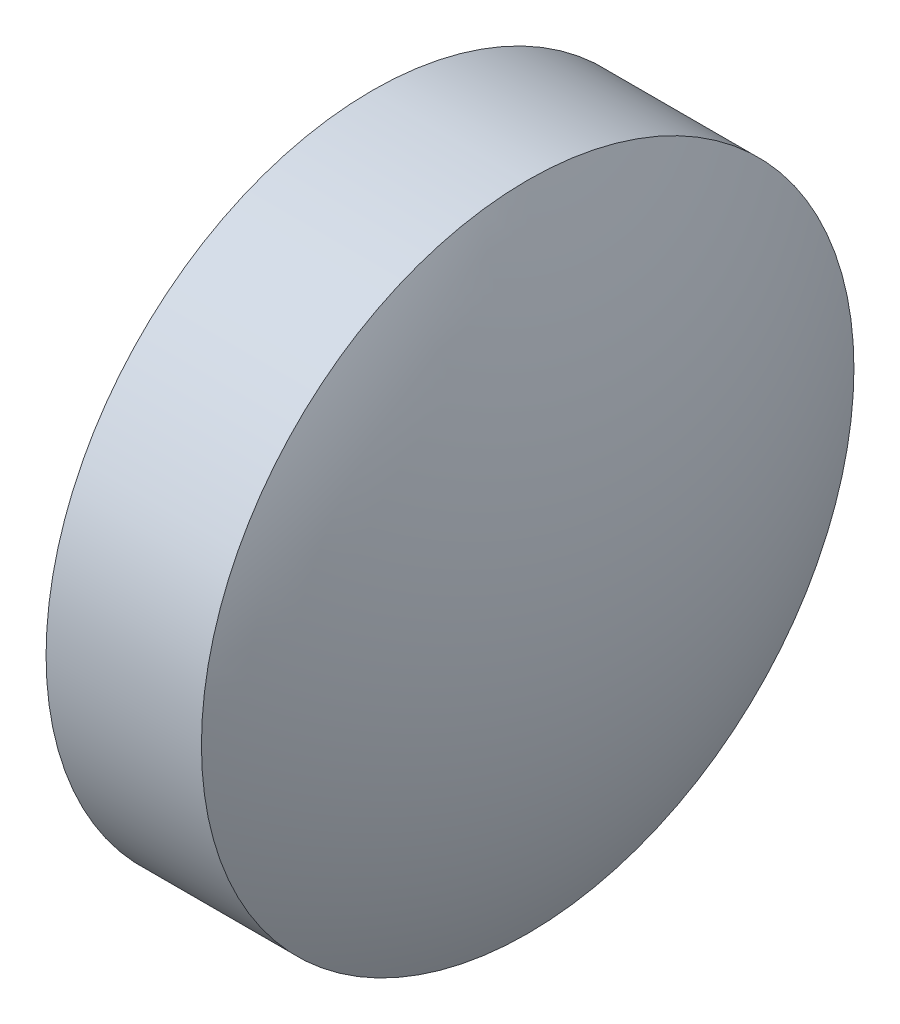
from build123d import *


with BuildPart() as part:
    # 草图1 → 旋转1 (revolve)
    with BuildSketch(Plane.XY, mode=Mode.PRIVATE) as revolve_1_sk:
        with BuildLine():
            Line((401.188455692, 12.445658556), (401.188455692, 15.595658556))
            Line((401.188455692, 15.595658556), (402.688455692, 15.595658556))
            ThreePointArc((402.688455692, 15.595658556), (403.255768328, 14.065851446), (403.448455692, 12.445658556))
            Line((403.448455692, 12.445658556), (401.188455692, 12.445658556))
        make_face()
    revolve(revolve_1_sk.sketch.rotate(Axis((400.327817604, 12.445658556, 0), (1, 0, 0)), 180), axis=Axis((400.327817604, 12.445658556, 0), (1, 0, 0)))  # turned: the seam where the file's is


solid = part.part
